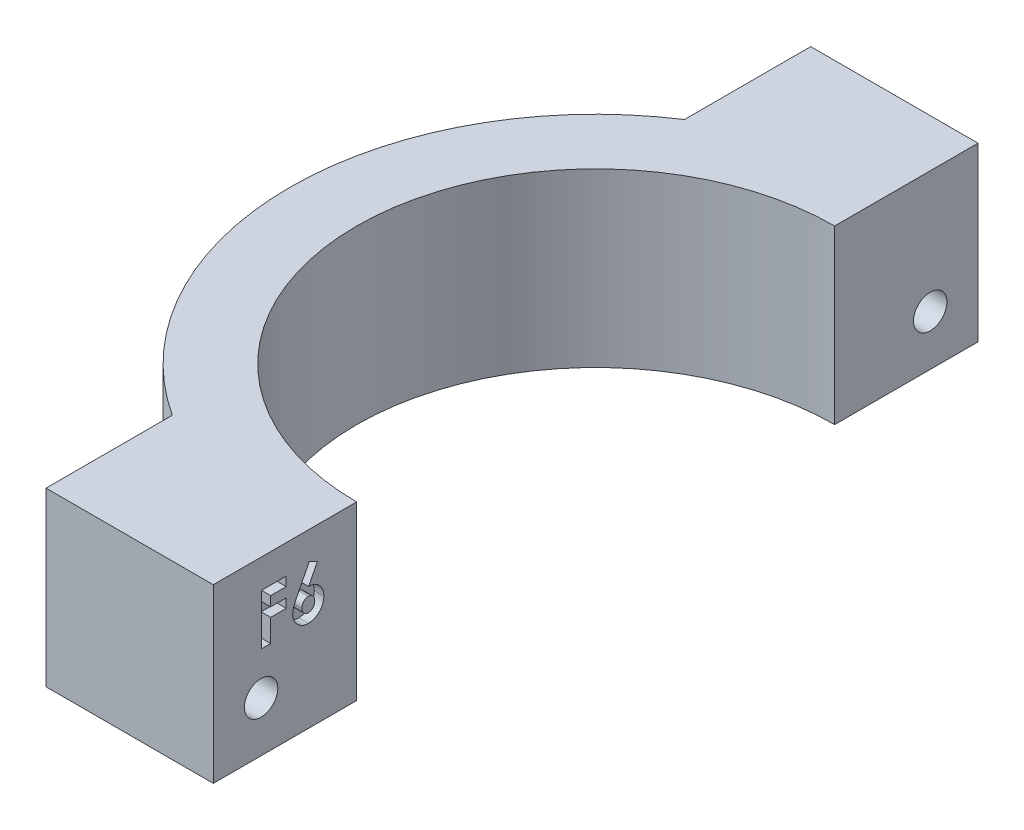
from build123d import *

# Parameters (mm, degrees)
BOSS_EXTRUDE1_DEPTH = 18
SKETCH2_R           = 1.75
CUT_EXTRUDE1_DEPTH  = 33
CUT_EXTRUDE2_DEPTH  = 1
CUT_EXTRUDE3_DEPTH  = 5


with BuildPart() as part:
    # Sketch1 → Boss-Extrude1 (new body)
    with BuildSketch(Plane(origin=(0, 0, 0), x_dir=(1, 0, 0), z_dir=(0, 1, 0))):
        with BuildLine():
            Line((-11.998275301, 32.528571429), (-29.498275301, 32.528571429))
            Line((-29.498275301, 32.528571429), (-29.498275301, 19.319428078))
            ThreePointArc((-29.498275301, 19.319428078), (-21.127694429, 23.198649785), (-11.998275301, 24.528571429))
            Line((-11.998275301, 24.528571429), (-11.998275301, 32.528571429))
        make_face()
        with BuildLine():
            ThreePointArc((-11.998275301, 24.528571429), (-21.127694429, 23.198649785), (-29.498275301, 19.319428078))
            ThreePointArc((-29.498275301, 19.319428078), (-43.998275301, -7.471428571), (-29.498275301, -34.262285221))
            ThreePointArc((-29.498275301, -34.262285221), (-21.127694429, -38.141506928), (-11.998275301, -39.471428571))
            Line((-11.998275301, -39.471428571), (-11.998275301, -32.471428571))
            ThreePointArc((-11.998275301, -32.471428571), (-36.998275301, -7.471428571), (-11.998275301, 17.528571429))
            Line((-11.998275301, 17.528571429), (-11.998275301, 24.528571429))
        make_face()
        with BuildLine():
            Line((-29.498275301, -34.262285221), (-29.498275301, -47.471428571))
            Line((-29.498275301, -47.471428571), (-11.998275301, -47.471428571))
            Line((-11.998275301, -47.471428571), (-11.998275301, -39.471428571))
            ThreePointArc((-11.998275301, -39.471428571), (-21.127694429, -38.141506928), (-29.498275301, -34.262285221))
        make_face()
    extrude(amount=BOSS_EXTRUDE1_DEPTH)

    # Sketch2 → Cut-Extrude1 (cut, through all)
    with BuildSketch(Plane(origin=(-11.998275301, 0, 0), x_dir=(0, 0, -1), z_dir=(1, 0, 0))):
        with Locations((-42.471428571, 5.25)):
            Circle(SKETCH2_R)
        with Locations((27.528571429, 5.25)):
            Circle(SKETCH2_R)
    extrude(amount=-CUT_EXTRUDE1_DEPTH, mode=Mode.SUBTRACT)

    # Sketch3 → Cut-Extrude2 (cut)
    with BuildSketch(Plane(origin=(-11.998275301, 0, 0), x_dir=(0, 0, -1), z_dir=(1, 0, 0))):
        Polygon((-42.417738354, 14.960699998), (-39.839746901, 14.960699998), (-39.839746901, 14.010913673), (-41.467952029, 14.010913673), (-41.467952029, 12.993285468), (-39.839746901, 12.993285468), (-39.839746901, 12.043499143), (-41.467952029, 12.043499143), (-41.467952029, 9.669033331), (-42.417738354, 9.669033331), align=None)
        with BuildLine():
            Line((-37.418639796, 15.096383759), (-36.576976468, 14.669191918))
            Line((-36.576976468, 14.669191918), (-37.499202029, 12.857601707))
            add(Edge.make_bspline(
                [(-37.499202029, 12.857601707), (-37.444714907, 12.856212797), (-37.337743504, 12.853486031), (-37.180235064, 12.830829794), (-37.029618939, 12.792146161), (-36.884094237, 12.740675931), (-36.745768611, 12.671572146), (-36.612417045, 12.589364414), (-36.48748866, 12.48910469), (-36.368119164, 12.378021865), (-36.259577083, 12.254958161), (-36.1652891, 12.122722275), (-36.083118786, 11.984531555), (-36.01924289, 11.837294329), (-35.967718466, 11.683451224), (-35.930541327, 11.522387264), (-35.909330729, 11.353636042), (-35.906406494, 11.238995693), (-35.904917841, 11.180635228)],
                knots=[0, 0, 0, 0, 0.000163413, 0.000320819, 0.000476106, 0.000629341, 0.000782939, 0.000939124, 0.001098386, 0.001262622, 0.001427858, 0.001589654, 0.001749279, 0.001909217, 0.002070118, 0.002235459, 0.00240428, 0.002579342, 0.002579342, 0.002579342, 0.002579342], degree=3))
            add(Edge.make_bspline(
                [(-35.904917841, 11.180635228), (-35.906312832, 11.12437928), (-35.909070131, 11.013185394), (-35.931862859, 10.849869855), (-35.968697104, 10.693178147), (-36.021340637, 10.543423201), (-36.088254824, 10.399873012), (-36.170086343, 10.262611816), (-36.267513827, 10.132665321), (-36.378020019, 10.010724), (-36.498822351, 9.899573584), (-36.626154588, 9.800776626), (-36.761095728, 9.71916659), (-36.901095226, 9.650245002), (-37.048730558, 9.598814566), (-37.201792353, 9.559993497), (-37.361441325, 9.537592055), (-37.469806956, 9.534775048), (-37.524642734, 9.533349571)],
                knots=[0, 0, 0, 0, 0.000168708, 0.000333463, 0.000493643, 0.000650875, 0.000808794, 0.000968046, 0.001129383, 0.001295239, 0.001461028, 0.001621313, 0.001777843, 0.001933346, 0.002088578, 0.00224592, 0.002406475, 0.002570947, 0.002570947, 0.002570947, 0.002570947], degree=3))
            add(Edge.make_bspline(
                [(-37.524642734, 9.533349571), (-37.581984294, 9.534519384), (-37.694738713, 9.536819664), (-37.859726647, 9.562576741), (-38.017964276, 9.601350429), (-38.168562277, 9.656712667), (-38.312457177, 9.727205977), (-38.44795487, 9.814434357), (-38.576196739, 9.917435913), (-38.695815537, 10.033893272), (-38.803583159, 10.161456375), (-38.899702871, 10.293900088), (-38.981020271, 10.431432244), (-39.046844811, 10.573905795), (-39.098202644, 10.720866743), (-39.133937221, 10.872594007), (-39.157221595, 11.028685132), (-39.159951157, 11.134617402), (-39.161328098, 11.188055433)],
                knots=[0, 0, 0, 0, 0.000171885, 0.000337989, 0.000499701, 0.000660001, 0.000818339, 0.000979478, 0.001142378, 0.001311042, 0.001479484, 0.001642759, 0.00180147, 0.001957982, 0.002112862, 0.002267641, 0.002425047, 0.002585283, 0.002585283, 0.002585283, 0.002585283], degree=3))
            add(Edge.make_bspline(
                [(-39.161328098, 11.188055433), (-39.160600549, 11.229436937), (-39.159141403, 11.312430291), (-39.144477856, 11.436708329), (-39.122184114, 11.561312585), (-39.096342748, 11.666457602), (-39.06973392, 11.755368717), (-39.042951931, 11.830611792), (-39.009761556, 11.914115152), (-38.97182004, 12.006092031), (-38.927934263, 12.106431782), (-38.878333474, 12.214860904), (-38.822894189, 12.332200505), (-38.783358344, 12.412794641), (-38.76275705, 12.454790543)],
                knots=[0, 0, 0, 0, 0.000124096, 0.000248883, 0.000374888, 0.000503693, 0.000573446, 0.000653238, 0.000743197, 0.000843003, 0.000951711, 0.001071724, 0.0012007, 0.001341029, 0.001341029, 0.001341029, 0.001341029], degree=3))
            Line((-38.76275705, 12.454790543), (-37.418639796, 15.096383759))
        make_face()
        with BuildLine():
            add(Edge.make_bspline(
                [(-37.545843322, 11.975657263), (-37.59141696, 11.973566896), (-37.680598589, 11.969476324), (-37.807401527, 11.926637853), (-37.923017038, 11.859434955), (-38.023233992, 11.765841923), (-38.107056253, 11.653994574), (-38.168651791, 11.526417732), (-38.20570493, 11.384813877), (-38.209554514, 11.285806822), (-38.211541773, 11.234696726)],
                knots=[0, 0, 0, 0, 0.000136279, 0.00026668, 0.000396852, 0.0005349, 0.000675037, 0.000813949, 0.000957414, 0.001110503, 0.001110503, 0.001110503, 0.001110503], degree=3))
            add(Edge.make_bspline(
                [(-38.211541773, 11.234696726), (-38.209188797, 11.183569611), (-38.204612101, 11.084123954), (-38.166165714, 10.941171776), (-38.103217051, 10.810697813), (-38.014935565, 10.697368244), (-37.911294369, 10.603295927), (-37.796368575, 10.533724951), (-37.672075188, 10.490985217), (-37.586098416, 10.485770403), (-37.542663234, 10.483135895)],
                knots=[0, 0, 0, 0, 0.000153173, 0.000297932, 0.000440631, 0.000585017, 0.000726133, 0.000858297, 0.000985677, 0.001115733, 0.001115733, 0.001115733, 0.001115733], degree=3))
            add(Edge.make_bspline(
                [(-37.542663234, 10.483135895), (-37.496790772, 10.485817325), (-37.406826908, 10.491076074), (-37.277048133, 10.532017398), (-37.158494443, 10.600422832), (-37.053670049, 10.694193969), (-36.963627887, 10.806230295), (-36.901327806, 10.937470644), (-36.861104027, 11.081454599), (-36.856885283, 11.182470747), (-36.854704166, 11.234696726)],
                knots=[0, 0, 0, 0, 0.000137436, 0.000269537, 0.00040391, 0.000545113, 0.000689312, 0.000832011, 0.000978068, 0.001134411, 0.001134411, 0.001134411, 0.001134411], degree=3))
            add(Edge.make_bspline(
                [(-36.854704166, 11.234696726), (-36.857188856, 11.285776979), (-36.86200075, 11.384699854), (-36.898143772, 11.526967091), (-36.962674696, 11.654052204), (-37.048393503, 11.766303611), (-37.152059393, 11.85985491), (-37.272302072, 11.927167836), (-37.40489758, 11.969400428), (-37.498176409, 11.973541243), (-37.545843322, 11.975657263)],
                knots=[0, 0, 0, 0, 0.000153173, 0.000296638, 0.000436486, 0.000577899, 0.000718308, 0.000852158, 0.000988622, 0.001131234, 0.001131234, 0.001131234, 0.001131234], degree=3))
        make_face(mode=Mode.SUBTRACT)
    extrude(amount=-CUT_EXTRUDE2_DEPTH, mode=Mode.SUBTRACT)

    # Sketch4 → Cut-Extrude3 (cut)
    with BuildSketch(Plane.ZY.offset(29.498275301)):
        Polygon((-25.283205831, 3.004634402), (-24.461344982, 6.071860849), (-26.706710579, 8.317226447), (-29.773937026, 7.495365598), (-30.595797876, 4.428139151), (-28.350432278, 2.182773553), align=None)
        Polygon((44.349661379, 2.689614315), (45.627904022, 5.596404483), (43.749671214, 8.156790168), (40.593195764, 7.810385685), (39.314953121, 4.903595517), (41.193185928, 2.343209832), align=None)
    extrude(amount=-CUT_EXTRUDE3_DEPTH, mode=Mode.SUBTRACT)


solid = part.part
